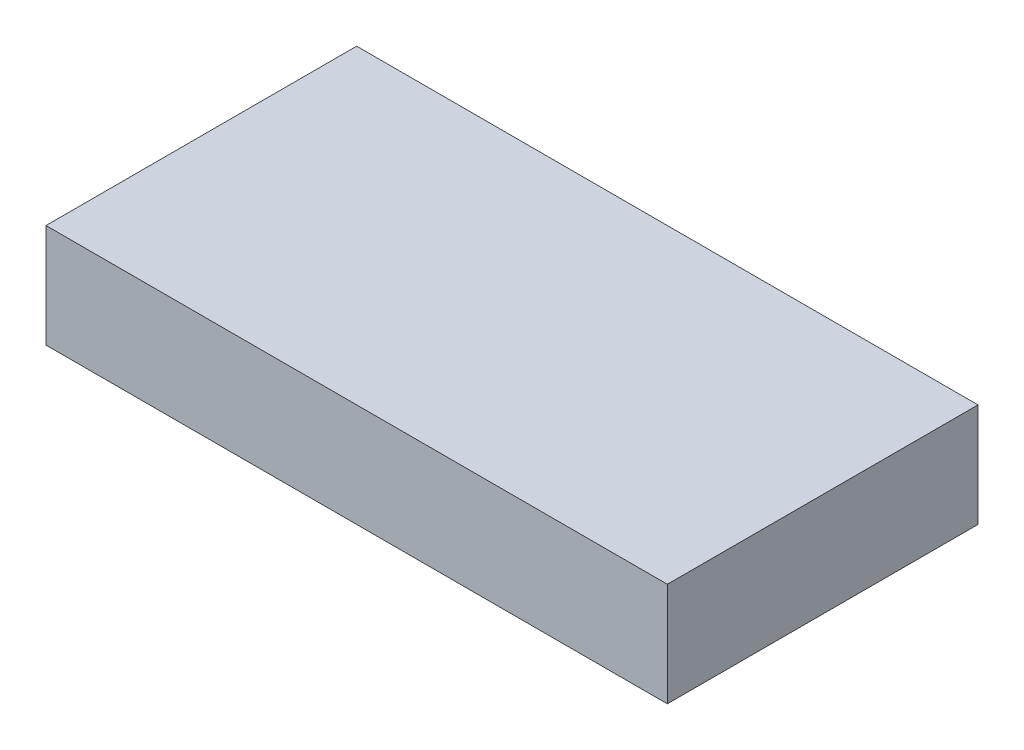
from build123d import *

# Parameters (mm, degrees)
SKETCH1_W           = 30
SKETCH1_H           = 15
BOSS_EXTRUDE1_DEPTH = 5


with BuildPart() as part:
    # Sketch1 → Boss-Extrude1 (new body)
    with BuildSketch(Plane(origin=(0, 0, 0), x_dir=(1, 0, 0), z_dir=(0, 1, 0))):
        Rectangle(SKETCH1_W, SKETCH1_H)
    extrude(amount=BOSS_EXTRUDE1_DEPTH)


solid = part.part
